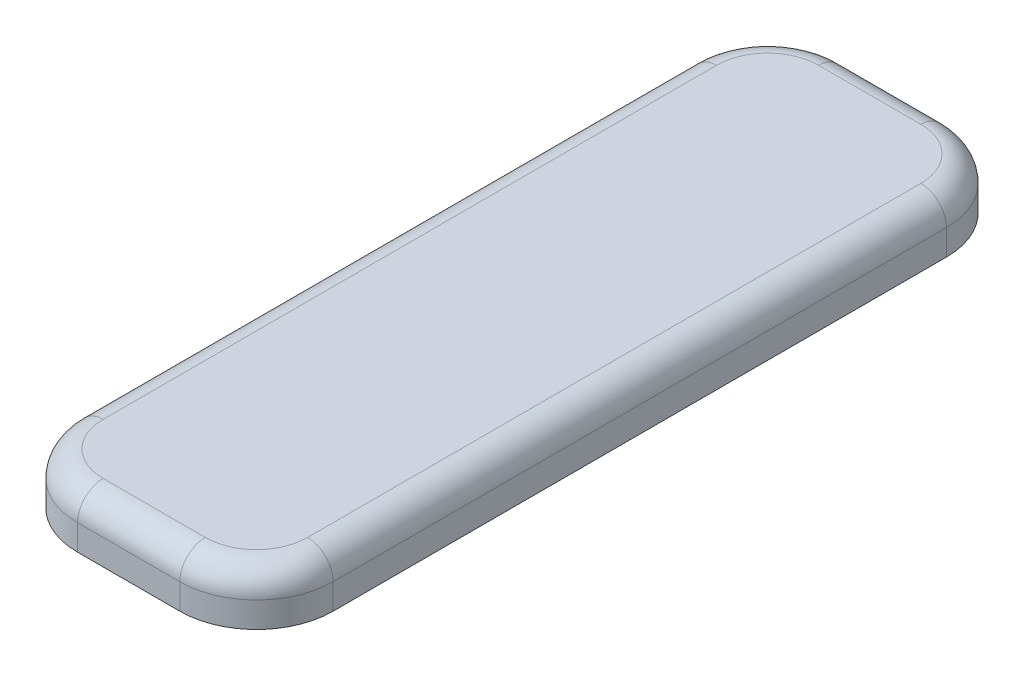
from build123d import *

# Parameters (mm, degrees)
BOSS_EXTRUDE1_DEPTH = 20
FILLET1_R           = 10


with BuildPart() as part:
    # Sketch1 → Boss-Extrude1 (new body)
    with BuildSketch(Plane(origin=(0, 0, 0), x_dir=(1, 0, 0), z_dir=(0, 1, 0))):
        with BuildLine():
            Line((-20, -150), (20, -150))
            ThreePointArc((20, -150), (41.213203436, -141.213203436), (50, -120))
            Line((50, -120), (50, 120))
            ThreePointArc((50, 120), (41.213203436, 141.213203436), (20, 150))
            Line((20, 150), (-20, 150))
            ThreePointArc((-20, 150), (-41.213203436, 141.213203436), (-50, 120))
            Line((-50, 120), (-50, -120))
            ThreePointArc((-50, -120), (-41.213203436, -141.213203436), (-20, -150))
        make_face()
    extrude(amount=BOSS_EXTRUDE1_DEPTH)

    # Fillet1
    fillet1_edges = [part.edges().sort_by_distance(p)[0] for p in [
        (-41.213203436, 20, 141.213203436),
        (0, 20, 150),
        (41.213203436, 20, 141.213203436),
        (50, 20, 0),
        (41.213203436, 20, -141.213203436),
        (0, 20, -150),
        (-41.213203436, 20, -141.213203436),
        (-50, 20, 0),
    ]]
    fillet(fillet1_edges, radius=FILLET1_R)


solid = part.part
